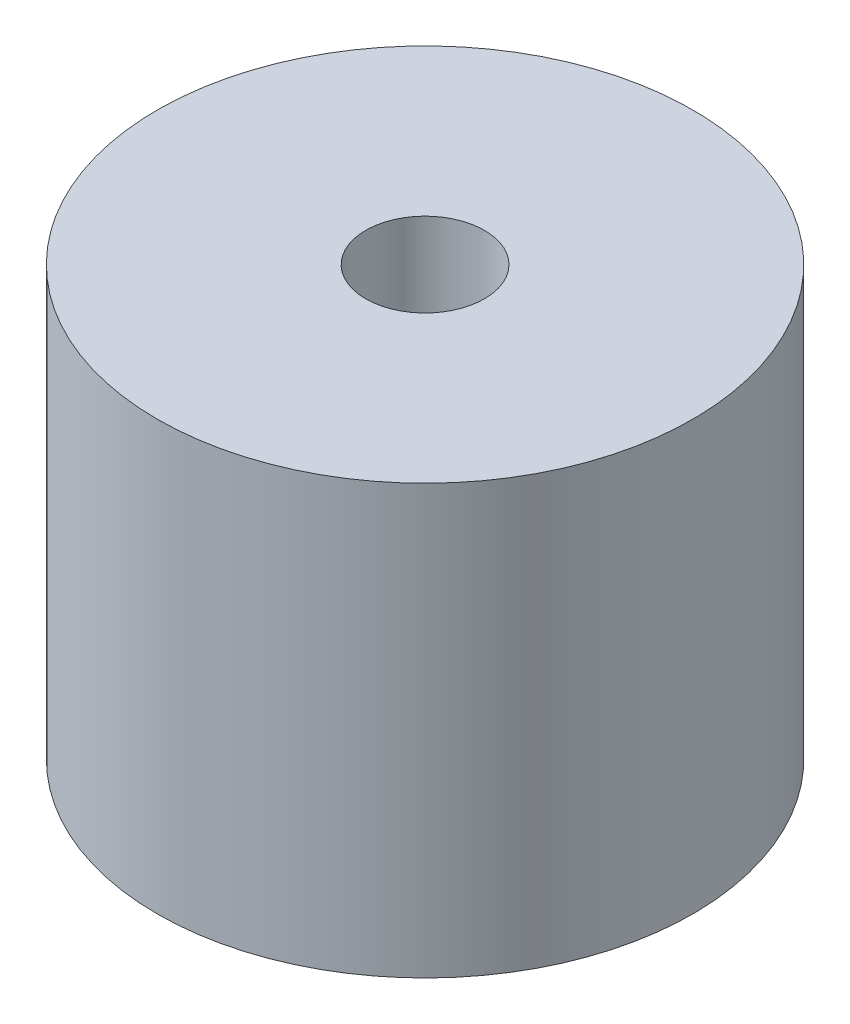
from build123d import *

# Parameters (mm, degrees)
SKETCH1_R           = 6
BOSS_EXTRUDE1_DEPTH = 9.6
SKETCH2_R           = 1.33
CUT_EXTRUDE1_DEPTH  = 3
SKETCH3_R           = 5
CUT_EXTRUDE2_DEPTH  = 1
SKETCH4_R           = 0.3
BOSS_EXTRUDE2_DEPTH = 1


with BuildPart() as part:
    # Sketch1 → Boss-Extrude1 (new body)
    with BuildSketch(Plane(origin=(0, 0, 0), x_dir=(1, 0, 0), z_dir=(0, 1, 0))):
        Circle(SKETCH1_R)
    extrude(amount=BOSS_EXTRUDE1_DEPTH)

    # Sketch2 → Cut-Extrude1 (cut)
    with BuildSketch(Plane(origin=(0, 9.6, 0), x_dir=(1, 0, 0), z_dir=(0, 1, 0))):
        Circle(SKETCH2_R)
    extrude(amount=-CUT_EXTRUDE1_DEPTH, mode=Mode.SUBTRACT)

    # Sketch3 → Cut-Extrude2 (cut)
    with BuildSketch(Plane(origin=(0, 6.6, 0), x_dir=(1, 0, 0), z_dir=(0, 1, 0))):
        Circle(SKETCH3_R)
    extrude(amount=CUT_EXTRUDE2_DEPTH, mode=Mode.SUBTRACT)

    # Sketch4 → Boss-Extrude2 (add)
    with BuildSketch(Plane.XZ):
        with Locations((-3.75, 0)):
            Circle(SKETCH4_R)
        with Locations((3.75, 0)):
            Circle(SKETCH4_R)
    extrude(amount=BOSS_EXTRUDE2_DEPTH)


solid = part.part
